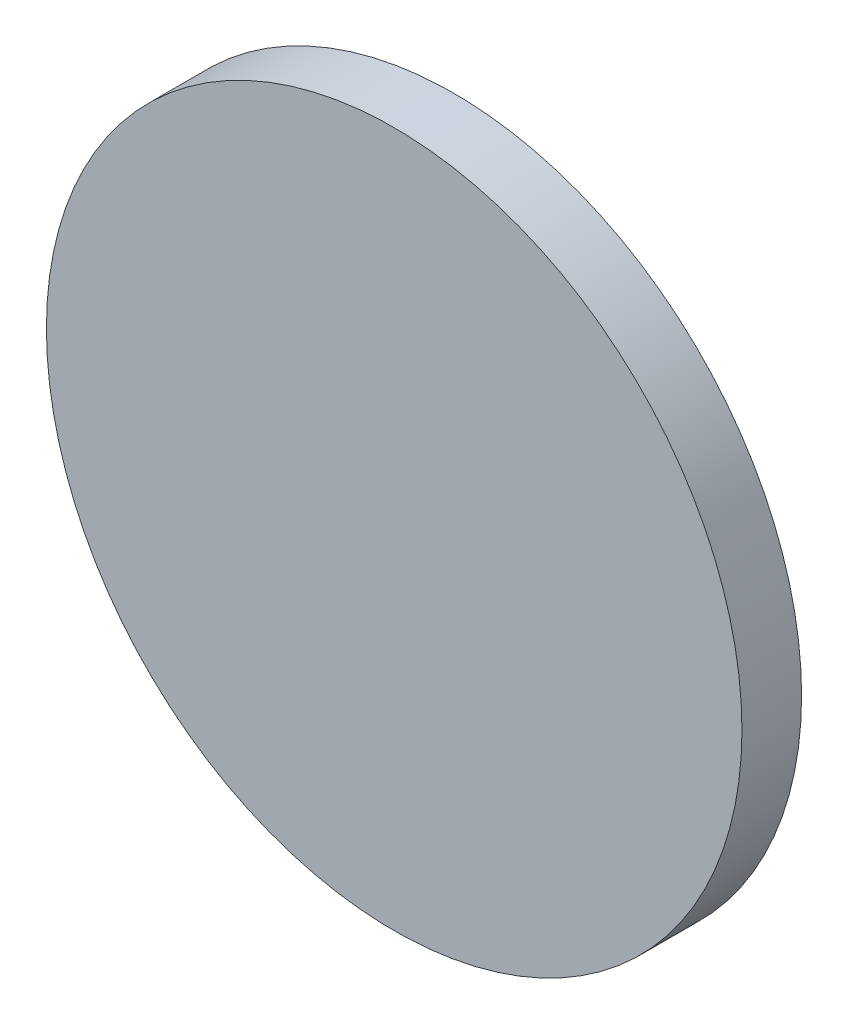
from build123d import *


with BuildPart() as part:
    # Sketch1 → Revolve2 (revolve)
    with BuildSketch(Plane(origin=(0, 0, 0), x_dir=(0, 0, -1), z_dir=(1, 0, 0))):
        Polygon((0, 66.675), (11.43, 66.675), (11.43, 63.5), (5.08, 63.5), (5.08, 0), (0, 0), align=None)
    revolve(axis=Axis((0, 0, 0), (0, 0, -1)))


solid = part.part
